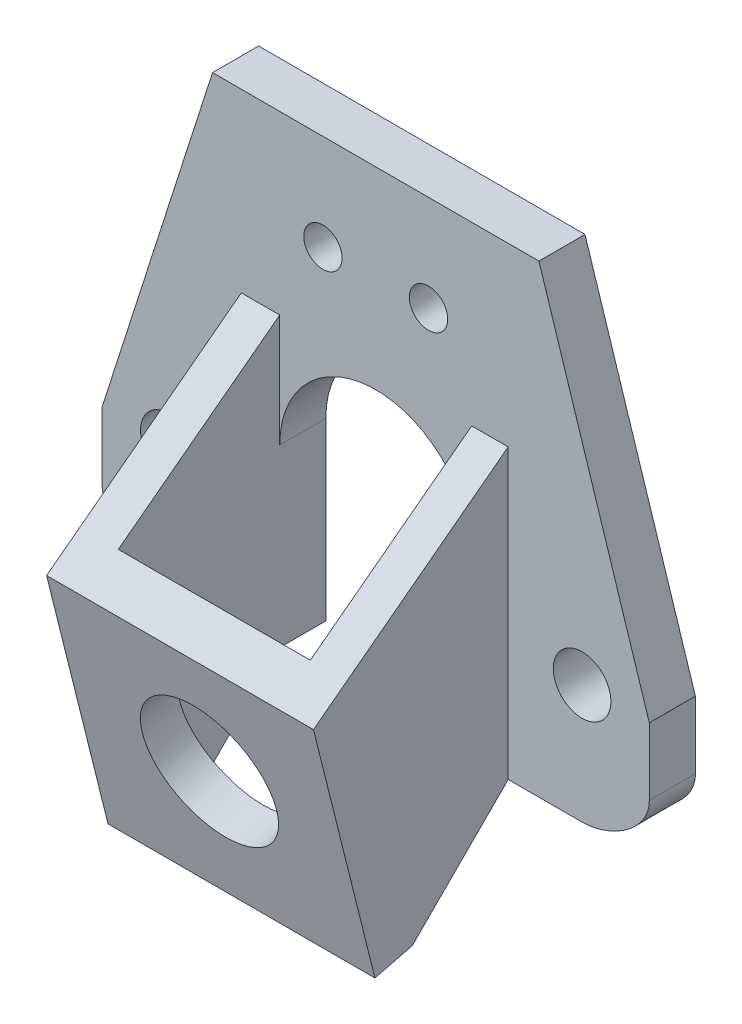
from build123d import *

# Parameters (mm, degrees)
SKETCH_1_R          = 1.5
SKETCH_1_R_2        = 1
EXTRUDE_2_DEPTH     = 2.4
SKETCH_2_W          = 1.9
SKETCH_2_H          = 20
SKETCH_2_W_2        = 2
EXTRUDE_3_DEPTH     = 10
CUT_EXTRUDE_1_DEPTH = 15
CUT_EXTRUDE_2_DEPTH = 20
SKETCH_8_W          = 13.9
SKETCH_8_H          = 20.615528128
EXTRUDE_5_DEPTH     = 2
SKETCH_9_R          = 3.5
CUT_EXTRUDE_4_DEPTH = 2
CUT_EXTRUDE_5_DEPTH = 20


with BuildPart() as part:
    # 草图1 → 凸台-拉伸2 (new body)
    with BuildSketch(Plane.XY):
        with BuildLine():
            Line((14.436511473, 15.948106541), (20.186511473, 15.948106541))
            Line((20.186511473, 15.948106541), (20.186511473, 25.081955572))
            ThreePointArc((20.186511473, 25.081955572), (25.186511473, 30.081955572), (30.186511473, 25.081955572))
            Line((30.186511473, 25.081955572), (30.186511473, 15.948106541))
            Line((30.186511473, 15.948106541), (35.936511473, 15.948106541))
            add(Edge.make_bspline(
                [(39.436511473, 18.679045823), (39.436511473, 17.199254946), (37.41630235, 15.948106541), (35.936511473, 15.948106541)],
                knots=[0, 0, 0, 0, 4.439372631, 4.439372631, 4.439372631, 4.439372631], degree=3))
            Line((39.436511473, 18.679045823), (39.436511473, 22.179045823))
            Line((39.436511473, 22.179045823), (33.686511473, 40.132696196))
            Line((33.686511473, 40.132696196), (25.186511473, 40.132696196))
            Line((25.186511473, 40.132696196), (16.686511473, 40.132696196))
            Line((16.686511473, 40.132696196), (10.936511473, 22.179045823))
            Line((10.936511473, 22.179045823), (10.936511473, 18.679045823))
            add(Edge.make_bspline(
                [(10.936511473, 18.679045823), (10.936511473, 17.199254946), (12.956720596, 15.948106541), (14.436511473, 15.948106541)],
                knots=[0, 0, 0, 0, 4.439372631, 4.439372631, 4.439372631, 4.439372631], degree=3))
        make_face()
        with Locations((14.436511473, 22.132696196)):
            Circle(SKETCH_1_R, mode=Mode.SUBTRACT)
        with Locations((35.936511473, 22.132696196)):
            Circle(SKETCH_1_R, mode=Mode.SUBTRACT)
        with Locations((27.936511473, 35.132696196)):
            Circle(SKETCH_1_R_2, mode=Mode.SUBTRACT)
        with Locations((22.436511473, 35.132696196)):
            Circle(SKETCH_1_R_2, mode=Mode.SUBTRACT)
    extrude(amount=EXTRUDE_2_DEPTH)

    # 草图2 → 凸台-拉伸3 (add)
    with BuildSketch(Plane.XY.offset(2.4)):
        with Locations((31.136511473, 20.948106541)):
            Rectangle(SKETCH_2_W, SKETCH_2_H)
        with Locations((19.186511473, 20.948106541)):
            Rectangle(SKETCH_2_W_2, SKETCH_2_H)
    extrude(amount=EXTRUDE_3_DEPTH)

    # 草图4 → 切除-拉伸1 (cut)
    with BuildSketch(Plane.ZY.offset(-18.186511473)):
        Polygon((2.4, 15.948106541), (7.4, 10.948106541), (2.4, 10.948106541), align=None)
    extrude(amount=-CUT_EXTRUDE_1_DEPTH, mode=Mode.SUBTRACT)

    # 草图5 → 切除-拉伸2 (cut)
    with BuildSketch(Plane.ZY.offset(-18.186511473)):
        Polygon((12.4, 10.948106541), (12.4, 30.948106541), (7.4, 10.948106541), align=None)
    extrude(amount=-CUT_EXTRUDE_2_DEPTH, mode=Mode.SUBTRACT)

    # 草图8 → 凸台-拉伸5 (add)
    with BuildSketch(Plane(origin=(0, -1.097170203, 4.388680814), x_dir=(1, 0, 0), z_dir=(0, -0.242535625, 0.9701425))):
        with Locations((25.136511473, 22.723751141)):
            Rectangle(SKETCH_8_W, SKETCH_8_H)
    extrude(amount=EXTRUDE_5_DEPTH)

    # 草图9 → 切除-拉伸4 (cut)
    with BuildSketch(Plane(origin=(0, -1.582241454, 6.328965814), x_dir=(1, 0, 0), z_dir=(0, -0.242535625, 0.9701425))):
        with Locations((25.136511473, 19.304044077)):
            Circle(SKETCH_9_R)
    extrude(amount=-CUT_EXTRUDE_4_DEPTH, mode=Mode.SUBTRACT)

    # 草图10 → 切除-拉伸5 (cut)
    with BuildSketch(Plane.ZY.offset(-18.186511473)):
        Polygon((2.4, 30.948106541), (12.541594878, 23.268274803), (18.273865584, 30.948106541), align=None)
    extrude(amount=-CUT_EXTRUDE_5_DEPTH, mode=Mode.SUBTRACT)


solid = part.part
